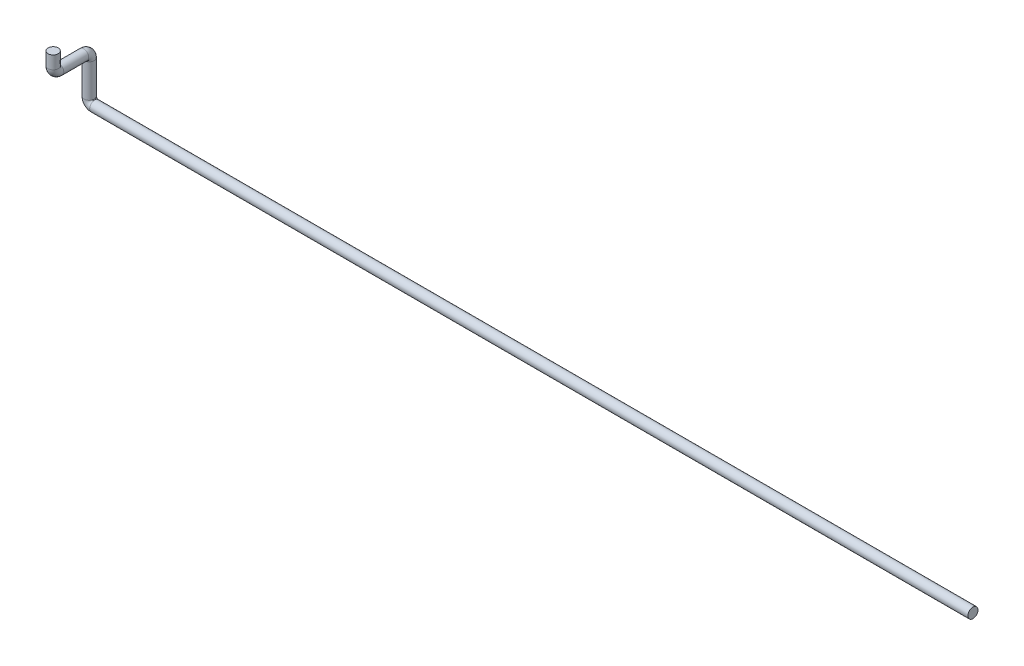
from build123d import *

# Parameters (mm, degrees)
CROQUIS1_R = 13.7


with BuildPart() as part:
    # Barrer1: sweep along a curve in space
    with BuildLine() as barrer1_path:
        Line((0, 0, 0), (-2374, 0, 0))
        ThreePointArc((-2374, 0, 0), (-2384.606601718, 4.393398282, 0), (-2389, 15, 0))
        Line((-2389, 15, 0), (-2389, 105, 0))
        ThreePointArc((-2389, 105, 0), (-2389, 115.606601718, 4.393398282), (-2389, 120, 15))
        Line((-2389, 120, 15), (-2389, 120, 82.5))
        ThreePointArc((-2389, 120, 82.5), (-2389, 124.393398282, 93.106601718), (-2389, 135, 97.5))
        Line((-2389, 135, 97.5), (-2389, 170, 97.5))
    # Croquis1 → Barrer1 (sweep)
    with BuildSketch(Plane(origin=(0, 0, 0), x_dir=(0, 0, -1), z_dir=(1, 0, 0))):
        Circle(CROQUIS1_R)
    sweep(path=barrer1_path.line)


solid = part.part
